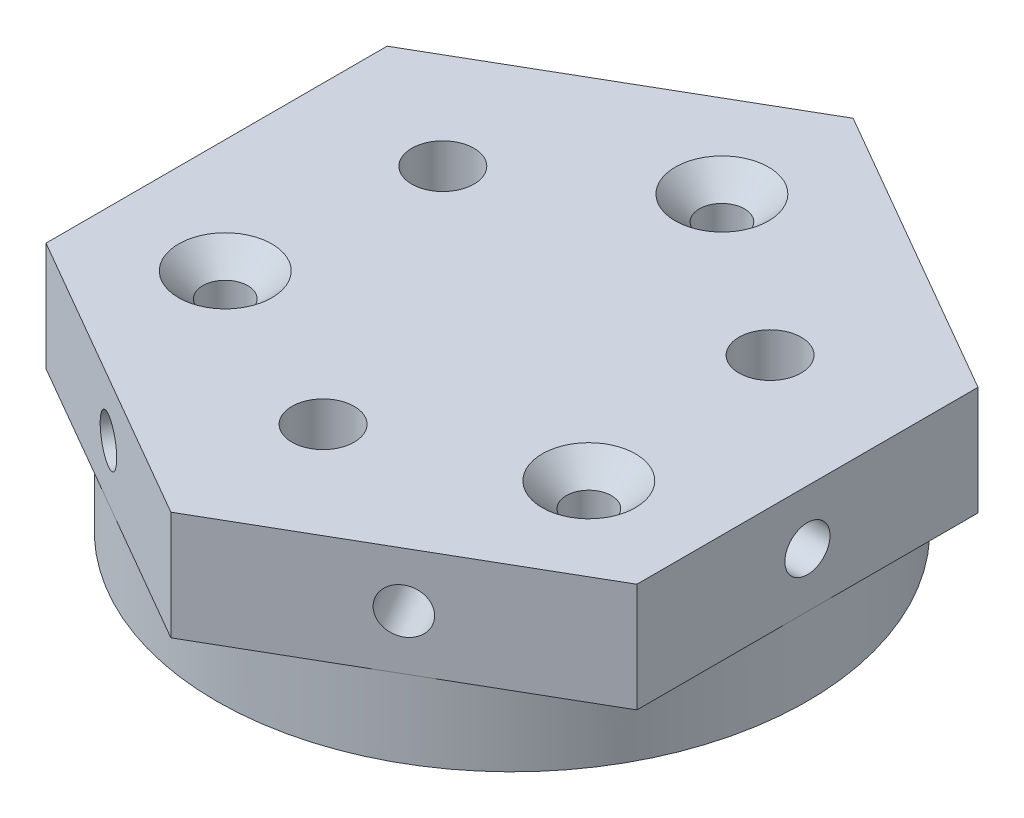
from build123d import *

# Parameters (mm, degrees)
SKETCH_1_R          = 19
SKETCH_1_R_2        = 1.45
SKETCH_1_R_3        = 2
EXTRUDE_1_DEPTH     = 12
SKETCH_2_R          = 1.45
SKETCH_2_R_2        = 2
EXTRUDE_2_DEPTH     = 7
SKETCH_3_R          = 1.45
CUT_EXTRUDE_1_DEPTH = 50.298411063
SKETCH_4_R          = 1.45
CUT_EXTRUDE_2_DEPTH = 50.298411063
SKETCH_5_R          = 1.45
CUT_EXTRUDE_3_DEPTH = 8
SKETCH_6_R          = 1.45
CUT_EXTRUDE_4_DEPTH = 46.489925625
CHAMFER_1_SIZE      = 1.55


with BuildPart() as part:
    # 草图1 → 凸台-拉伸1 (new body)
    with BuildSketch(Plane(origin=(0, 0, 0), x_dir=(1, 0, 0), z_dir=(0, 1, 0))):
        with Locations(Location((0, 0, 0), (0, 0, 270))):
            Circle(SKETCH_1_R)
        with Locations(Location((0, 13.5, 0), (0, 0, 270))):
            Circle(SKETCH_1_R_2, mode=Mode.SUBTRACT)
        with Locations(Location((-11.691342951, -6.75, 0), (0, 0, 270))):
            Circle(SKETCH_1_R_2, mode=Mode.SUBTRACT)
        with Locations(Location((11.691342951, -6.75, 0), (0, 0, 270))):
            Circle(SKETCH_1_R_2, mode=Mode.SUBTRACT)
        with Locations(Location((-10.522208656, 6.075, 0), (0, 0, 270))):
            Circle(SKETCH_1_R_3, mode=Mode.SUBTRACT)
        with Locations(Location((0, -12.15, 0), (0, 0, 270))):
            Circle(SKETCH_1_R_3, mode=Mode.SUBTRACT)
        with Locations(Location((10.522208656, 6.075, 0), (0, 0, 270))):
            Circle(SKETCH_1_R_3, mode=Mode.SUBTRACT)
    extrude(amount=EXTRUDE_1_DEPTH)

    # 草图2 → 凸台-拉伸2 (add)
    with BuildSketch(Plane(origin=(0, 12, 0), x_dir=(1, 0, 0), z_dir=(0, 1, 0))):
        Polygon((0, 21.939310229), (-19, 10.969655115), (-19, -10.969655115), (0, -21.939310229), (19, -10.969655115), (19, 10.969655115), align=None)
        with Locations(Location((0, 13.5, 0), (0, 0, 270))):
            Circle(SKETCH_2_R, mode=Mode.SUBTRACT)
        with Locations(Location((-10.522208656, 6.075, 0), (0, 0, 270))):
            Circle(SKETCH_2_R_2, mode=Mode.SUBTRACT)
        with Locations(Location((10.522208656, 6.075, 0), (0, 0, 270))):
            Circle(SKETCH_2_R_2, mode=Mode.SUBTRACT)
        with Locations(Location((-11.691342951, -6.75, 0), (0, 0, 270))):
            Circle(SKETCH_2_R, mode=Mode.SUBTRACT)
        with Locations(Location((0, -12.15, 0), (0, 0, 270))):
            Circle(SKETCH_2_R_2, mode=Mode.SUBTRACT)
        with Locations(Location((11.691342951, -6.75, 0), (0, 0, 270))):
            Circle(SKETCH_2_R, mode=Mode.SUBTRACT)
    extrude(amount=-EXTRUDE_2_DEPTH)

    # 草图3 → 切除-拉伸1 (cut, through all)
    with BuildSketch(Plane(origin=(9.5, 0, 16.454482672), x_dir=(0.8660254037844384, 0, -0.5000000000000004), z_dir=(0.5000000000000004, 0, 0.8660254037844384))):
        with Locations((0, 8.5)):
            Circle(SKETCH_3_R)
    extrude(amount=-CUT_EXTRUDE_1_DEPTH, mode=Mode.SUBTRACT)

    # 草图4 → 切除-拉伸2 (cut, through all)
    with BuildSketch(Plane(origin=(-9.5, 0, 16.454482672), x_dir=(0.8660254037844385, 0, 0.5000000000000004), z_dir=(-0.5000000000000003, 0, 0.8660254037844384))):
        with Locations((0, 8.5)):
            Circle(SKETCH_4_R)
    extrude(amount=-CUT_EXTRUDE_2_DEPTH, mode=Mode.SUBTRACT)

    # 草图5 → 切除-拉伸3 (cut)
    with BuildSketch(Plane.ZY.offset(19)):
        with Locations((0, 8.5)):
            Circle(SKETCH_5_R)
    extrude(amount=-CUT_EXTRUDE_3_DEPTH, mode=Mode.SUBTRACT)

    # 草图6 → 切除-拉伸4 (cut, through all)
    with BuildSketch(Plane(origin=(19, 0, 0), x_dir=(0, 0, -1), z_dir=(1, 0, 0))):
        with Locations(Location((0, 8.5, 0), (0, 0, 180))):
            Circle(SKETCH_6_R)
    extrude(amount=-CUT_EXTRUDE_4_DEPTH, mode=Mode.SUBTRACT)

    # 倒角1
    chamfer_1_edges = [part.edges().sort_by_distance(p)[0] for p in [
        (11.691342951, 12, 5.3),
        (0, 12, -14.95),
        (-11.691342951, 12, 5.3),
    ]]
    chamfer(chamfer_1_edges, length=CHAMFER_1_SIZE)


solid = part.part
